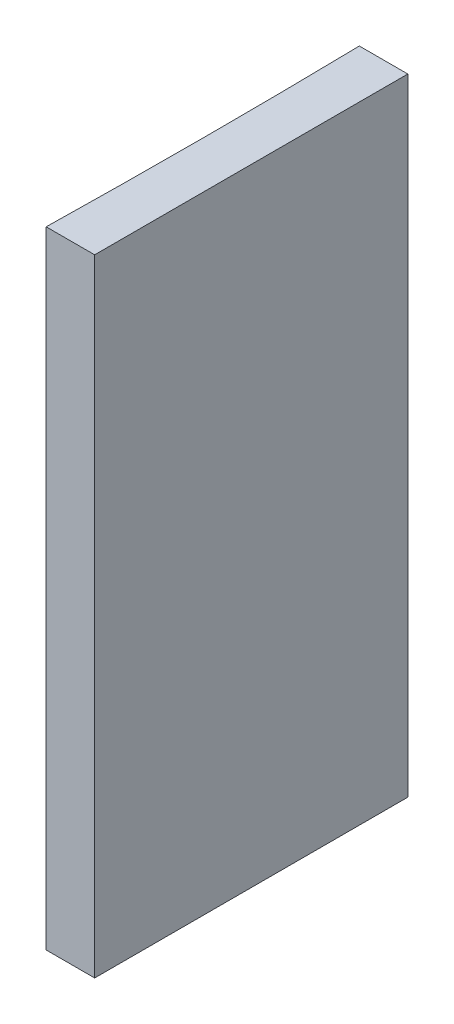
from build123d import *

# Parameters (mm, degrees)
EXTRUDE_1_DEPTH = 40


with BuildPart() as part:
    # 草图1 → 凸台-拉伸1 (new body)
    with BuildSketch(Plane(origin=(0, 0, 0), x_dir=(1, 0, 0), z_dir=(0, 1, 0))):
        with BuildLine():
            Line((0, 0), (0, -20))
            Line((0, -20), (-3.096758284, -20))
            ThreePointArc((-3.096758284, -20), (-3, -10), (-3.096758284, 0))
            Line((-3.096758284, 0), (0, 0))
        make_face()
    extrude(amount=EXTRUDE_1_DEPTH)


solid = part.part
